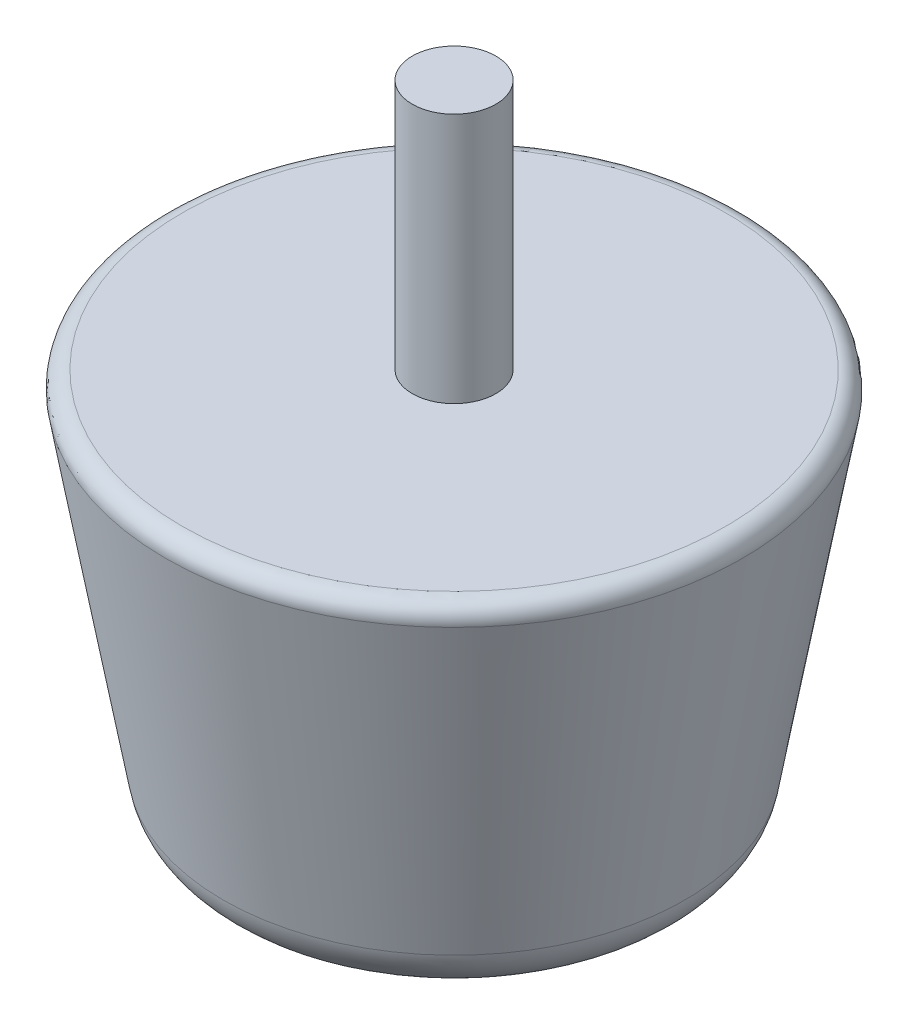
from build123d import *

# Parameters (mm, degrees)
SKETCH1_R           = 40
BOSS_EXTRUDE1_DEPTH = 70
BOSS_EXTRUDE1_TAPER = -10
CUT_EXTRUDE1_REACH  = 99.343
CUT_EXTRUDE1_START  = -45
SKETCH2_R           = 9
SKETCH3_R           = 7.5
BOSS_EXTRUDE2_DEPTH = 45
FILLET1_R           = 10
FILLET2_R           = 3


with BuildPart() as part:
    # Sketch1 → Boss-Extrude1 (new body)
    with BuildSketch(Plane(origin=(0, 0, 0), x_dir=(1, 0, 0), z_dir=(0, 1, 0))):
        Circle(SKETCH1_R)
    extrude(amount=BOSS_EXTRUDE1_DEPTH, taper=BOSS_EXTRUDE1_TAPER)

    # Sketch2 → Cut-Extrude1 (cut, up to next)
    with BuildSketch(Plane(origin=(0, 0, 0), x_dir=(0, 0, -1), z_dir=(1, 0, 0)).offset(CUT_EXTRUDE1_START), mode=Mode.PRIVATE) as cut_extrude1_sk1:
        with Locations((0, 42.296816006)):
            Circle(SKETCH2_R)
    cut_extrude1_tool1 = extrude(cut_extrude1_sk1.sketch, amount=-CUT_EXTRUDE1_REACH, mode=Mode.PRIVATE) & part.part
    add(cut_extrude1_tool1.solids().sort_by_distance((-45, 42.296816, 0))[0], mode=Mode.SUBTRACT)

    # Sketch3 → Boss-Extrude2 (add)
    with BuildSketch(Plane(origin=(0, 70, 0), x_dir=(1, 0, 0), z_dir=(0, 1, 0))):
        Circle(SKETCH3_R)
    extrude(amount=BOSS_EXTRUDE2_DEPTH)

    # Fillet1
    fillet1_edges = [part.edges().sort_by_distance(p)[0] for p in [
        (-40, 0, 0),
    ]]
    fillet(fillet1_edges, radius=FILLET1_R)

    # Fillet2
    fillet2_edges = [part.edges().sort_by_distance(p)[0] for p in [
        (-52.34288865, 70, 0),
    ]]
    fillet(fillet2_edges, radius=FILLET2_R)


solid = part.part
